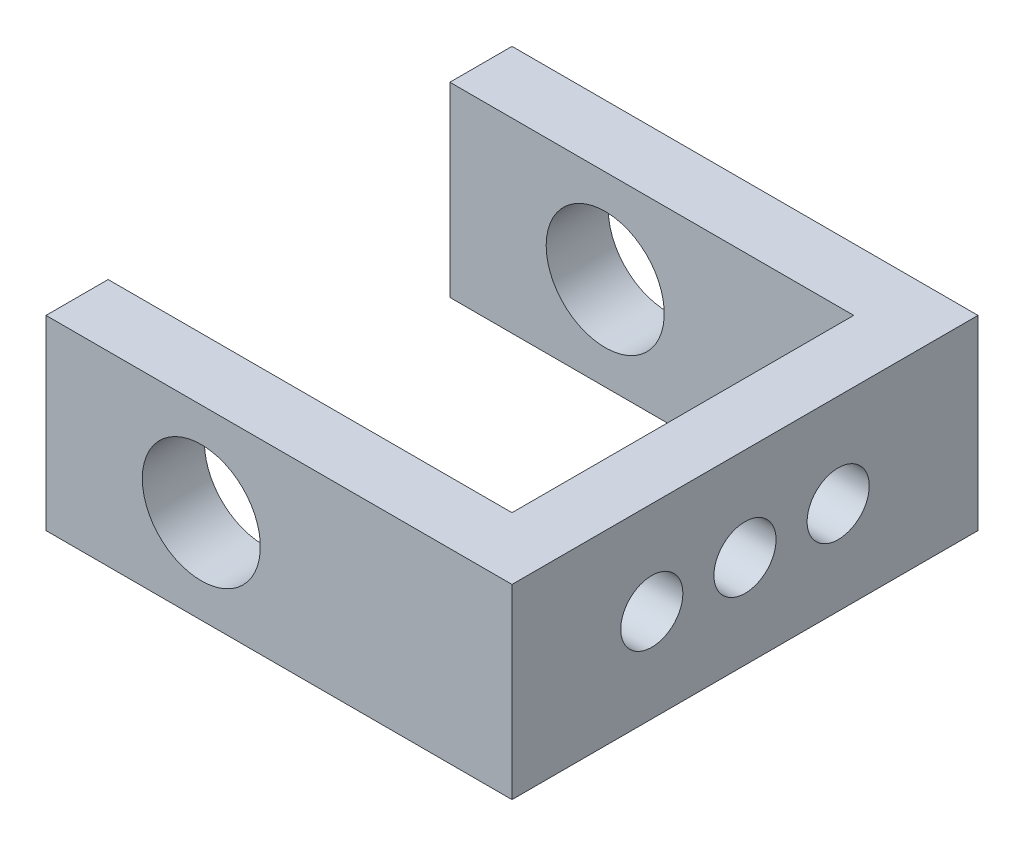
from build123d import *

# Parameters (mm, degrees)
BOSS_EXTRUDE1_DEPTH              = 30
SKETCH3_R                        = 9.5
CUT_EXTRUDE1_DEPTH               = 90
M10X1_0_TAPPED_HOLE1_D           = 9
M10X1_0_TAPPED_HOLE1_DEPTH       = 23
M10X1_0_TAPPED_HOLE1_CBORE_D     = 10
M10X1_0_TAPPED_HOLE1_CBORE_DEPTH = 20
M10X1_0_TAPPED_HOLE1_TIP         = 2.703872786


with BuildPart() as part:
    # Sketch1 → Boss-Extrude1 (new body)
    with BuildSketch(Plane(origin=(0, 0, 0), x_dir=(1, 0, 0), z_dir=(0, 1, 0))):
        Polygon((-55.756575978, -25.748980809), (19.243424022, -25.748980809), (19.243424022, 49.251019191), (-55.756575978, 49.251019191), (-55.756575978, 39.251019191), (9.243424022, 39.251019191), (9.243424022, -15.748980809), (-55.756575978, -15.748980809), align=None)
    extrude(amount=BOSS_EXTRUDE1_DEPTH)

    # Sketch3 → Cut-Extrude1 (cut)
    with BuildSketch(Plane(origin=(0, 0, -49.251019191), x_dir=(-1, 0, 0), z_dir=(0, 0, -1))):
        with Locations((30.756575978, 15)):
            Circle(SKETCH3_R)
    extrude(amount=-CUT_EXTRUDE1_DEPTH, mode=Mode.SUBTRACT)

    # M10x1.0 Tapped Hole1
    with Locations(Plane(origin=(19.243424022, 0, 0), x_dir=(0, 0, -1), z_dir=(1, 0, 0))):
        with Locations((-3.248980809, 15), (11.751019191, 15), (26.751019191, 15)):
            CounterBoreHole(M10X1_0_TAPPED_HOLE1_D / 2, M10X1_0_TAPPED_HOLE1_CBORE_D / 2, M10X1_0_TAPPED_HOLE1_CBORE_DEPTH, depth=M10X1_0_TAPPED_HOLE1_DEPTH)
            with Locations((0, 0, -(M10X1_0_TAPPED_HOLE1_DEPTH + M10X1_0_TAPPED_HOLE1_TIP / 2))):  # 118° drill point
                Cone(0, M10X1_0_TAPPED_HOLE1_D / 2, M10X1_0_TAPPED_HOLE1_TIP, mode=Mode.SUBTRACT)


solid = part.part
